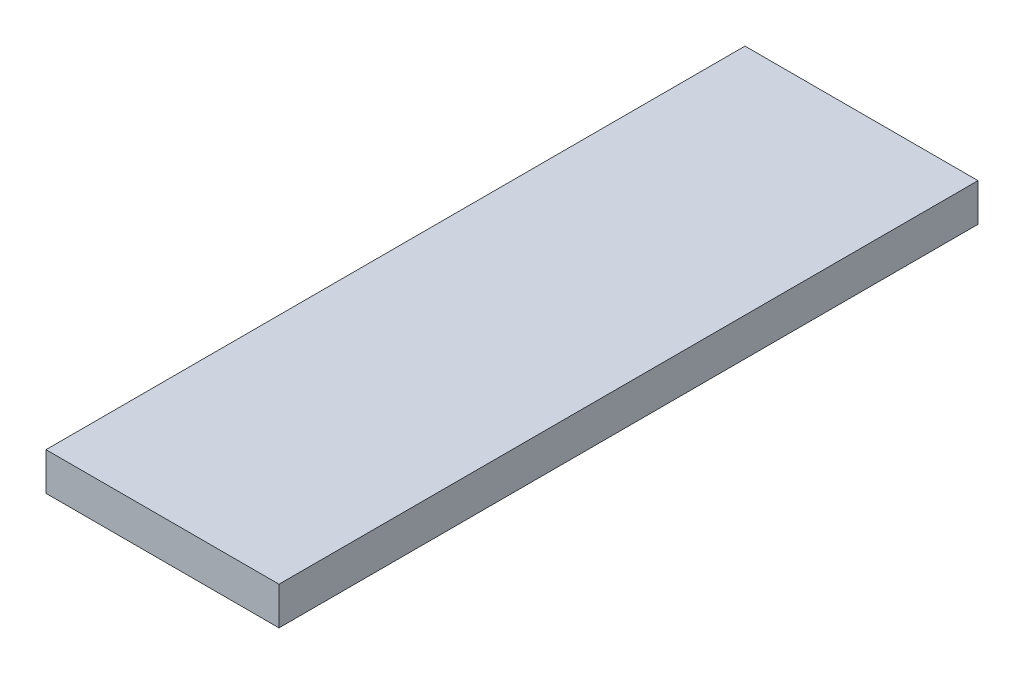
from build123d import *

# Parameters (mm, degrees)
SKETCH1_W           = 40
SKETCH1_H           = 120
BOSS_EXTRUDE1_DEPTH = 6.5


with BuildPart() as part:
    # Sketch1 → Boss-Extrude1 (new body)
    with BuildSketch(Plane(origin=(0, 0, 0), x_dir=(1, 0, 0), z_dir=(0, 1, 0))):
        with Locations((20, 60)):
            Rectangle(SKETCH1_W, SKETCH1_H)
    extrude(amount=BOSS_EXTRUDE1_DEPTH)


solid = part.part
